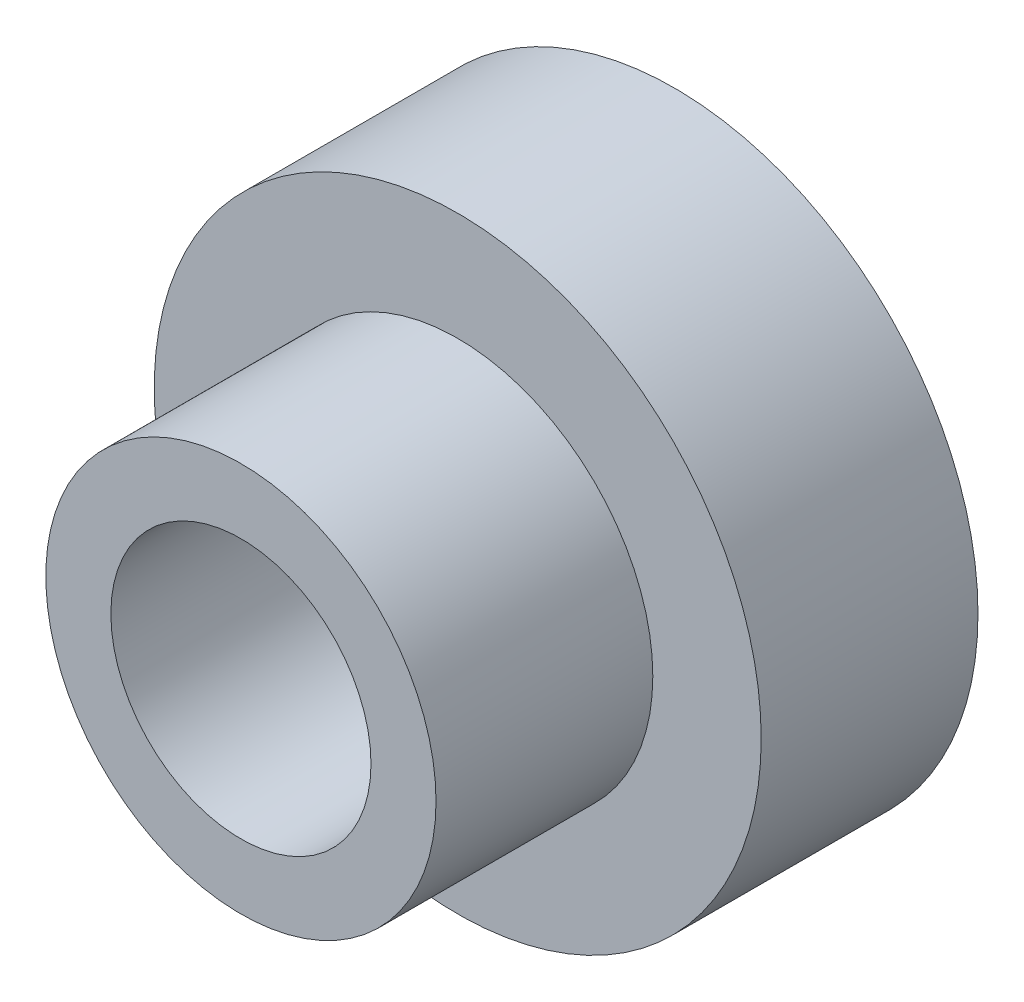
from build123d import *

# Parameters (mm, degrees)
SKETCH_1_R          = 14
EXTRUDE_1_DEPTH     = 10
SKETCH_2_R          = 9
EXTRUDE_2_DEPTH     = 10
SKETCH_3_R          = 6
CUT_EXTRUDE_1_DEPTH = 21


with BuildPart() as part:
    # 草图1 → 凸台-拉伸1 (new body)
    with BuildSketch(Plane.XY):
        Circle(SKETCH_1_R)
    extrude(amount=EXTRUDE_1_DEPTH)

    # 草图2 → 凸台-拉伸2 (add)
    with BuildSketch(Plane.XY.offset(10)):
        Circle(SKETCH_2_R)
    extrude(amount=EXTRUDE_2_DEPTH)

    # 草图3 → 切除-拉伸1 (cut, through all)
    with BuildSketch(Plane.XY.offset(20)):
        Circle(SKETCH_3_R)
    extrude(amount=-CUT_EXTRUDE_1_DEPTH, mode=Mode.SUBTRACT)


solid = part.part
